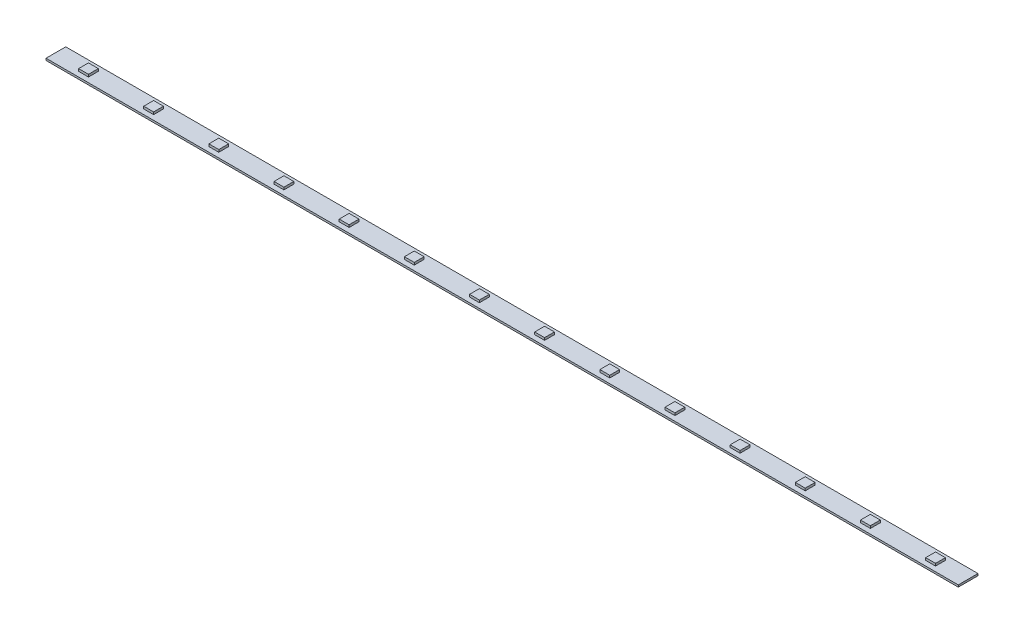
from build123d import *

# Parameters (mm, degrees)
SKETCH1_W           = 33
SKETCH1_H           = 10
BOSS_EXTRUDE1_DEPTH = 1
SKETCH3_W           = 5
SKETCH3_H           = 5
BOSS_EXTRUDE2_DEPTH = 1.2
LPATTERN1_COUNT     = 8
LPATTERN1_PITCH     = 33
LPATTERN1_COL_COUNT = 7
LPATTERN1_COL_PITCH = 33


with BuildPart() as part:
    # Sketch1 → Boss-Extrude1 (new body)
    with BuildSketch(Plane(origin=(0, 0, 0), x_dir=(1, 0, 0), z_dir=(0, 1, 0))):
        Rectangle(SKETCH1_W, SKETCH1_H)
    boss_extrude1 = extrude(amount=BOSS_EXTRUDE1_DEPTH)

    # Sketch3 → Boss-Extrude2 (add)
    with BuildSketch(Plane(origin=(0, 1, 0), x_dir=(1, 0, 0), z_dir=(0, 1, 0))):
        Rectangle(SKETCH3_W, SKETCH3_H)
    boss_extrude2 = extrude(amount=BOSS_EXTRUDE2_DEPTH)

    # LPattern1: Boss-Extrude1, Boss-Extrude2 ×8
    with Locations(*[(-i * LPATTERN1_PITCH, 0, 0) for i in range(1, LPATTERN1_COUNT)]):
        add(boss_extrude1)
        add(boss_extrude2)

    # LPattern1 col: Boss-Extrude1, Boss-Extrude2 ×7
    with Locations(*[(i * LPATTERN1_COL_PITCH, 0, 0) for i in range(1, LPATTERN1_COL_COUNT)]):
        add(boss_extrude1)
        add(boss_extrude2)


solid = part.part
